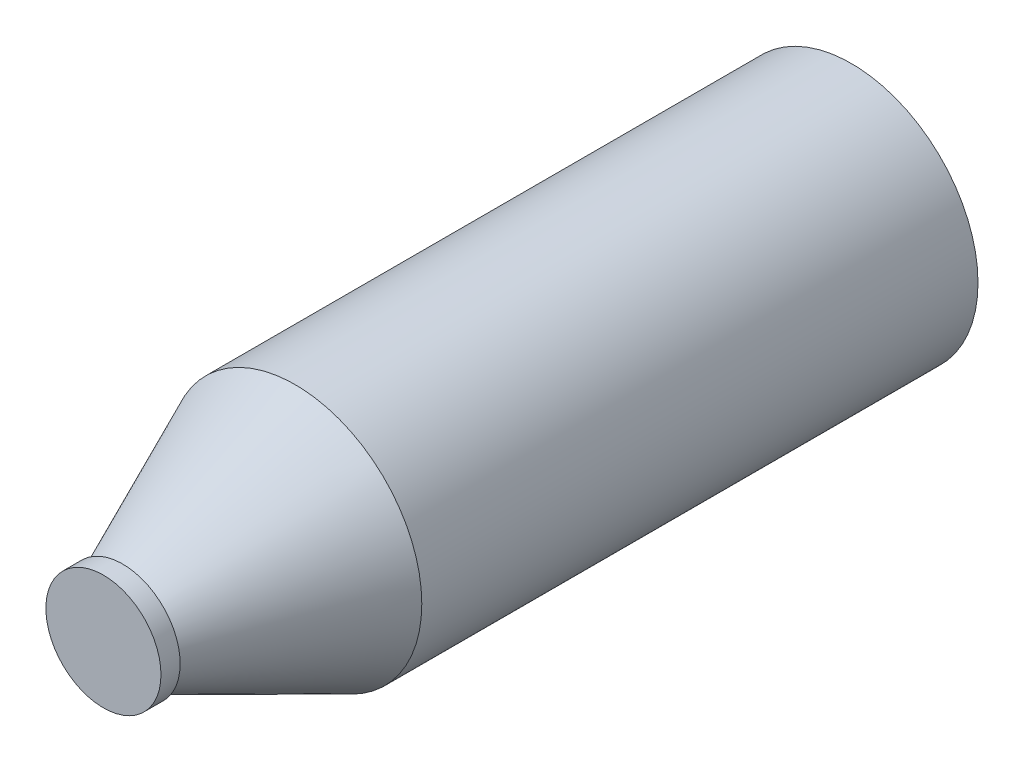
from build123d import *

# Parameters (mm, degrees)
ESQUISSE2_R        = 33
BOSS_EXTRU_1_DEPTH = 145
ESQUISSE4_R        = 33
BOSS_EXTRU_2_DEPTH = 45
BOSS_EXTRU_2_TAPER = 24
ESQUISSE5_R        = 15
BOSS_EXTRU_3_DEPTH = 5


with BuildPart() as part:
    # Esquisse2 → Boss.-Extru.1 (new body)
    with BuildSketch(Plane.XY):
        with Locations((41.050709504, 36.47878936)):
            Circle(ESQUISSE2_R)
    extrude(amount=BOSS_EXTRU_1_DEPTH)

    # Esquisse4 → Boss.-Extru.2 (add)
    with BuildSketch(Plane.XY.offset(145)):
        with Locations((41.050709504, 36.47878936)):
            Circle(ESQUISSE4_R)
    extrude(amount=BOSS_EXTRU_2_DEPTH, taper=BOSS_EXTRU_2_TAPER)

    # Esquisse5 → Boss.-Extru.3 (add)
    with BuildSketch(Plane.XY.offset(190)):
        with Locations((41.050709504, 36.47878936)):
            Circle(ESQUISSE5_R)
    extrude(amount=BOSS_EXTRU_3_DEPTH)


solid = part.part
